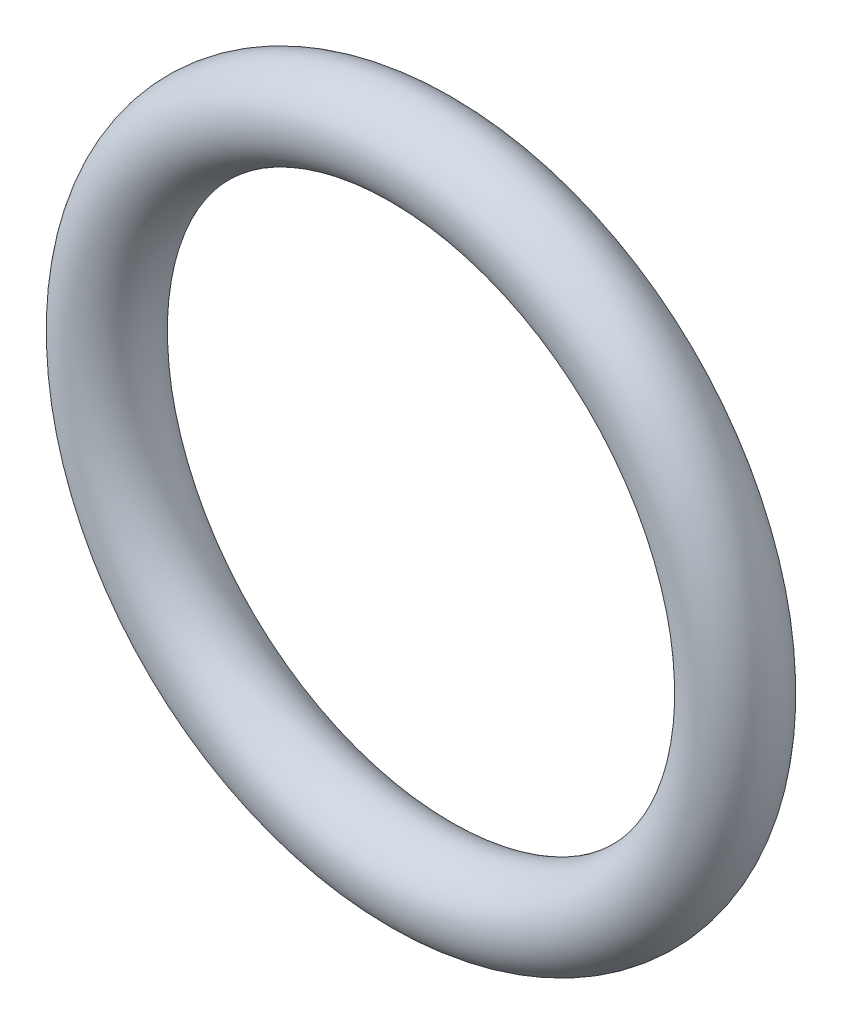
from build123d import *

# Parameters (mm, degrees)
SKETCH2_R = 2.38125


with BuildPart() as part:
    # Sweep1: sweep along a path in Sketch1
    with BuildLine(Plane.XY) as sweep1_path:
        CenterArc((0, 0), 17.4625, 0, 360)
    # Sketch2 → Sweep1 (sweep)
    with BuildSketch(Plane(origin=(0, 0, 0), x_dir=(0, 0, -1), z_dir=(1, 0, 0))):
        with Locations((0, 17.4625)):
            Circle(SKETCH2_R)
    sweep(path=sweep1_path.line)


solid = part.part
